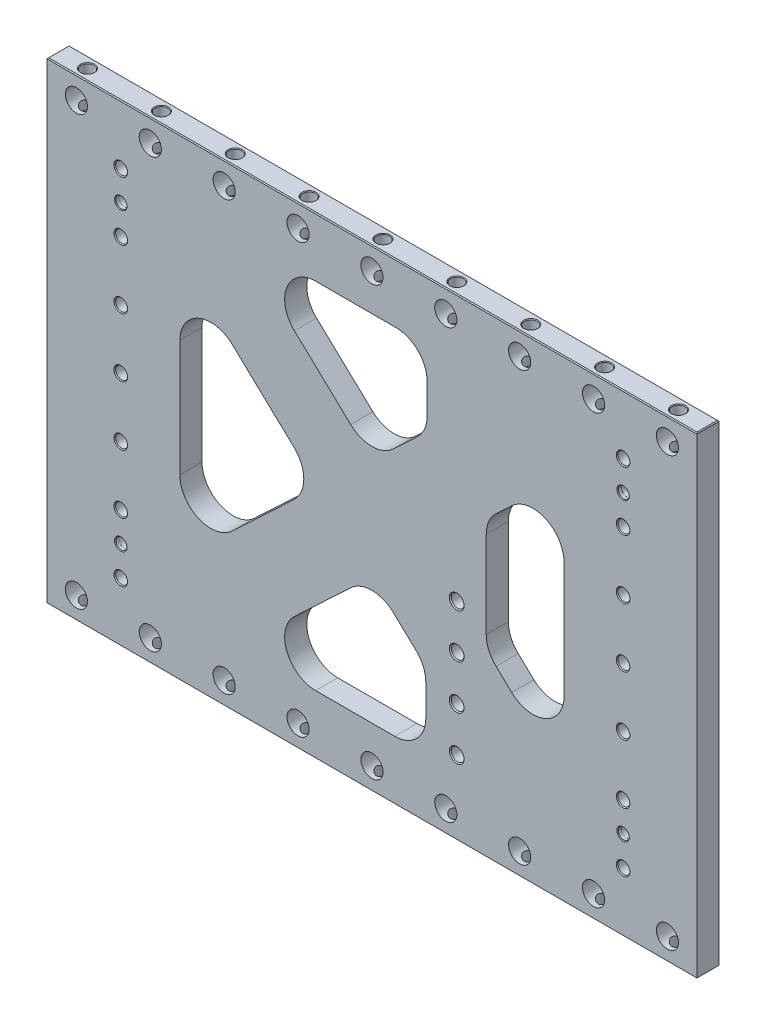
from build123d import *

# Parameters (mm, degrees)
SKETCH2_W                                = 558.8
SKETCH2_H                                = 406.4
EXTRUDE1_DEPTH                           = 9.525
TRIANGLES_CUT_EXTRUDE2_DEPTH             = 20.05
TRIANGLES_FILLET1_R                      = 26.67
LPATTERN3_COUNT                          = 4
LPATTERN3_PITCH                          = 50.8
LPATTERN3_COL_COUNT                      = 4
LPATTERN3_COL_PITCH                      = 50.8
F_3_4_0_75_DIAMETER_HOLE1_D              = 19.05
LPATTERN4_COUNT                          = 5
LPATTERN4_PITCH                          = 63.5
LPATTERN4_COL_COUNT                      = 5
LPATTERN4_COL_PITCH                      = 63.5
MIRROR2_COPY_1_D                         = 19.05
MIRROR2_COPY_2_D                         = 19.05
MIRROR2_COPY_3_D                         = 19.05
MIRROR2_COPY_4_D                         = 19.05
MIRROR2_COPY_9_D                         = 19.05
MIRROR2_COPY_10_D                        = 19.05
MIRROR2_COPY_11_D                        = 19.05
MIRROR2_COPY_12_D                        = 19.05
LPATTERN5_COUNT                          = 4
LPATTERN5_PITCH                          = 38.1
F_3_8_0_375_PIN_LEAD_IN_HOLE1_AT_2_COUNT = 2
F_3_8_0_375_PIN_LEAD_IN_HOLE1_AT_2_PITCH = 431.8
F_3_8_0_375_PIN_LEAD_IN_HOLE1_AT_3_COUNT = 2
F_3_8_0_375_PIN_LEAD_IN_HOLE1_AT_3_PITCH = 500.966306252
F_3_8_0_375_PIN_LEAD_IN_HOLE1_AT_4_COUNT = 2
F_3_8_0_375_PIN_LEAD_IN_HOLE1_AT_4_PITCH = 254
CHAMFER1_SIZE                            = 0.762


with BuildPart() as part:
    # Sketch2 → Extrude1 (new body, symmetric)
    with BuildSketch(Plane.XY):
        Rectangle(SKETCH2_W, SKETCH2_H)
    extrude(amount=EXTRUDE1_DEPTH, both=True)

    # Sketch8 → Triangles -- Cut-Extrude2 (cut, through all)
    with BuildSketch(Plane.XY.offset(9.525)):
        Polygon((-165.1, 111.787575697), (-46.325700822, 0), (-165.1, -111.787575697), align=None)
        Polygon((-115.599299178, 152.4), (0, 43.600659597), (47.466504, 88.275016303), (47.466504, 152.4), align=None)
        Polygon((165.1, 111.787575697), (165.1, -111.787575697), (98.266504, -48.885461815), (98.266504, 48.885461815), align=None)
        Polygon((0, -43.600659597), (-115.599299178, -152.4), (46.325700822, -152.4), (46.325700822, -87.201319194), align=None)
    extrude(amount=-TRIANGLES_CUT_EXTRUDE2_DEPTH, mode=Mode.SUBTRACT)

    # Triangles -- Fillet1
    triangles_fillet1_edges = [part.edges().sort_by_distance(p)[0] for p in [
        (-165.1, -111.787575697, 0),
        (-165.1, 111.787575697, 0),
        (-46.325700822, 0, 0),
        (-115.599299178, 152.4, 0),
        (47.466504, 152.4, 0),
        (47.466504, 88.275016303, 0),
        (0, 43.600659597, 0),
        (98.266504, 48.885461815, 0),
        (165.1, 111.787575697, 0),
        (165.1, -111.787575697, 0),
        (98.266504, -48.885461815, 0),
        (0, -43.600659597, 0),
        (46.325700822, -87.201319194, 0),
        (46.325700822, -152.4, 0),
        (-115.599299178, -152.4, 0),
    ]]
    fillet(triangles_fillet1_edges, radius=TRIANGLES_FILLET1_R)

    # Sketch3 → CBORE for 3/8 Socket Head Cap Screw2 (revolve, cut)
    with BuildSketch(Plane(origin=(-215.9, 0, -9.525), x_dir=(0, 1, 0), z_dir=(1, 0, 0))):
        Polygon((0, 0), (0, 19.05), (5.842, 19.05), (5.15874, 18.263999282), (5.15874, 4.318), (8.73125, 4.318), (8.73125, 0), align=None)
    cbore_for_3_8_socket_head_cap_screw2 = revolve(axis=Axis((-215.9, 0, -15.875), (0, 0, 1)), mode=Mode.SUBTRACT)

    # LPattern3: CBORE for 3/8 Socket Head Cap Screw2 ×4
    with Locations(*[(0, i * LPATTERN3_PITCH, 0) for i in range(1, LPATTERN3_COUNT)]):
        add(cbore_for_3_8_socket_head_cap_screw2, mode=Mode.SUBTRACT)

    # LPattern3 col: CBORE for 3/8 Socket Head Cap Screw2 ×4
    with Locations(*[(0, -i * LPATTERN3_COL_PITCH, 0) for i in range(1, LPATTERN3_COL_COUNT)]):
        add(cbore_for_3_8_socket_head_cap_screw2, mode=Mode.SUBTRACT)

    # Mirror1: CBORE for 3/8 Socket Head Cap Screw2 across plane
    add(cbore_for_3_8_socket_head_cap_screw2.mirror(Plane(origin=(0, 0, 0), x_dir=(0, 0, 1), z_dir=(1, 0, 0))), mode=Mode.SUBTRACT)

    # Mirror1 copy 1 sketch → Mirror1 copy 1 (revolve, cut)
    with BuildSketch(Plane(origin=(215.9, 50.8, -9.525), x_dir=(0, 1, 0), z_dir=(-1, 0, 0))):
        Polygon((0, 0), (0, -19.05), (5.842, -19.05), (5.15874, -18.263999282), (5.15874, -4.318), (8.73125, -4.318), (8.73125, 0), align=None)
    revolve(axis=Axis((215.9, 50.8, -15.875), (0, 0, -1)), mode=Mode.SUBTRACT)

    # Mirror1 copy 2 sketch → Mirror1 copy 2 (revolve, cut)
    with BuildSketch(Plane(origin=(215.9, 101.6, -9.525), x_dir=(0, 1, 0), z_dir=(-1, 0, 0))):
        Polygon((0, 0), (0, -19.05), (5.842, -19.05), (5.15874, -18.263999282), (5.15874, -4.318), (8.73125, -4.318), (8.73125, 0), align=None)
    revolve(axis=Axis((215.9, 101.6, -15.875), (0, 0, -1)), mode=Mode.SUBTRACT)

    # Mirror1 copy 3 sketch → Mirror1 copy 3 (revolve, cut)
    with BuildSketch(Plane(origin=(215.9, 152.4, -9.525), x_dir=(0, 1, 0), z_dir=(-1, 0, 0))):
        Polygon((0, 0), (0, -19.05), (5.842, -19.05), (5.15874, -18.263999282), (5.15874, -4.318), (8.73125, -4.318), (8.73125, 0), align=None)
    revolve(axis=Axis((215.9, 152.4, -15.875), (0, 0, -1)), mode=Mode.SUBTRACT)

    # Mirror1 copy 4 sketch → Mirror1 copy 4 (revolve, cut)
    with BuildSketch(Plane(origin=(215.9, -50.8, -9.525), x_dir=(0, 1, 0), z_dir=(-1, 0, 0))):
        Polygon((0, 0), (0, -19.05), (5.842, -19.05), (5.15874, -18.263999282), (5.15874, -4.318), (8.73125, -4.318), (8.73125, 0), align=None)
    revolve(axis=Axis((215.9, -50.8, -15.875), (0, 0, -1)), mode=Mode.SUBTRACT)

    # Mirror1 copy 5 sketch → Mirror1 copy 5 (revolve, cut)
    with BuildSketch(Plane(origin=(215.9, -101.6, -9.525), x_dir=(0, 1, 0), z_dir=(-1, 0, 0))):
        Polygon((0, 0), (0, -19.05), (5.842, -19.05), (5.15874, -18.263999282), (5.15874, -4.318), (8.73125, -4.318), (8.73125, 0), align=None)
    revolve(axis=Axis((215.9, -101.6, -15.875), (0, 0, -1)), mode=Mode.SUBTRACT)

    # Mirror1 copy 6 sketch → Mirror1 copy 6 (revolve, cut)
    with BuildSketch(Plane(origin=(215.9, -152.4, -9.525), x_dir=(0, 1, 0), z_dir=(-1, 0, 0))):
        Polygon((0, 0), (0, -19.05), (5.842, -19.05), (5.15874, -18.263999282), (5.15874, -4.318), (8.73125, -4.318), (8.73125, 0), align=None)
    revolve(axis=Axis((215.9, -152.4, -15.875), (0, 0, -1)), mode=Mode.SUBTRACT)

    # 3/4 (0.75) Diameter Hole1 (through all)
    with Locations(Plane.XY.offset(9.525)):
        with Locations((0, -184.15)):
            f_3_4_0_75_diameter_hole1 = Hole(F_3_4_0_75_DIAMETER_HOLE1_D / 2)

    # Sketch12 → 7/16 (0.4375) Diameter Hole1 (revolve, cut)
    with BuildSketch(Plane(origin=(0, -203.2, 0), x_dir=(0, 0, -1), z_dir=(1, 0, 0))):
        Polygon((0, 0), (0, 38.263531814), (5.55625, 34.925), (5.55625, 0.620911348), (6.096, 0), align=None)
    f_7_16_0_4375_diameter_hole1 = revolve(axis=Axis((0, -209.55, 0), (0, 1, 0)), mode=Mode.SUBTRACT)

    # LPattern4: 3/4 (0.75) Diameter Hole1, 7/16 (0.4375) Diameter Hole1 ×5
    with Locations(*[(i * LPATTERN4_PITCH, 0, 0) for i in range(1, LPATTERN4_COUNT)]):
        add(f_3_4_0_75_diameter_hole1, mode=Mode.SUBTRACT)
        add(f_7_16_0_4375_diameter_hole1, mode=Mode.SUBTRACT)

    # LPattern4 col: 3/4 (0.75) Diameter Hole1, 7/16 (0.4375) Diameter Hole1 ×5
    with Locations(*[(-i * LPATTERN4_COL_PITCH, 0, 0) for i in range(1, LPATTERN4_COL_COUNT)]):
        add(f_3_4_0_75_diameter_hole1, mode=Mode.SUBTRACT)
        add(f_7_16_0_4375_diameter_hole1, mode=Mode.SUBTRACT)

    # Mirror2: 3/4 (0.75) Diameter Hole1, 7/16 (0.4375) Diameter Hole1 across plane
    add(f_3_4_0_75_diameter_hole1.mirror(Plane.ZX), mode=Mode.SUBTRACT)
    add(f_7_16_0_4375_diameter_hole1.mirror(Plane.ZX), mode=Mode.SUBTRACT)

    # Mirror2 copy 1 (through all)
    with Locations(Plane(origin=(63.5, 0, 9.525), x_dir=(1, 0, 0), z_dir=(0, 0, 1))):
        with Locations((0, 184.15)):
            Hole(MIRROR2_COPY_1_D / 2)

    # Mirror2 copy 2 (through all)
    with Locations(Plane(origin=(127, 0, 9.525), x_dir=(1, 0, 0), z_dir=(0, 0, 1))):
        with Locations((0, 184.15)):
            Hole(MIRROR2_COPY_2_D / 2)

    # Mirror2 copy 3 (through all)
    with Locations(Plane(origin=(190.5, 0, 9.525), x_dir=(1, 0, 0), z_dir=(0, 0, 1))):
        with Locations((0, 184.15)):
            Hole(MIRROR2_COPY_3_D / 2)

    # Mirror2 copy 4 (through all)
    with Locations(Plane(origin=(254, 0, 9.525), x_dir=(1, 0, 0), z_dir=(0, 0, 1))):
        with Locations((0, 184.15)):
            Hole(MIRROR2_COPY_4_D / 2)

    # Mirror2 copy 5 sketch → Mirror2 copy 5 (revolve, cut)
    with BuildSketch(Plane(origin=(63.5, 203.2, 0), x_dir=(0, 0, -1), z_dir=(1, 0, 0))):
        Polygon((0, 0), (0, -38.263531814), (5.55625, -34.925), (5.55625, -0.620911348), (6.096, 0), align=None)
    revolve(axis=Axis((63.5, 209.55, 0), (0, 1, 0)), mode=Mode.SUBTRACT)

    # Mirror2 copy 6 sketch → Mirror2 copy 6 (revolve, cut)
    with BuildSketch(Plane(origin=(127, 203.2, 0), x_dir=(0, 0, -1), z_dir=(1, 0, 0))):
        Polygon((0, 0), (0, -38.263531814), (5.55625, -34.925), (5.55625, -0.620911348), (6.096, 0), align=None)
    revolve(axis=Axis((127, 209.55, 0), (0, 1, 0)), mode=Mode.SUBTRACT)

    # Mirror2 copy 7 sketch → Mirror2 copy 7 (revolve, cut)
    with BuildSketch(Plane(origin=(190.5, 203.2, 0), x_dir=(0, 0, -1), z_dir=(1, 0, 0))):
        Polygon((0, 0), (0, -38.263531814), (5.55625, -34.925), (5.55625, -0.620911348), (6.096, 0), align=None)
    revolve(axis=Axis((190.5, 209.55, 0), (0, 1, 0)), mode=Mode.SUBTRACT)

    # Mirror2 copy 8 sketch → Mirror2 copy 8 (revolve, cut)
    with BuildSketch(Plane(origin=(254, 203.2, 0), x_dir=(0, 0, -1), z_dir=(1, 0, 0))):
        Polygon((0, 0), (0, -38.263531814), (5.55625, -34.925), (5.55625, -0.620911348), (6.096, 0), align=None)
    revolve(axis=Axis((254, 209.55, 0), (0, 1, 0)), mode=Mode.SUBTRACT)

    # Mirror2 copy 9 (through all)
    with Locations(Plane(origin=(-63.5, 0, 9.525), x_dir=(1, 0, 0), z_dir=(0, 0, 1))):
        with Locations((0, 184.15)):
            Hole(MIRROR2_COPY_9_D / 2)

    # Mirror2 copy 10 (through all)
    with Locations(Plane(origin=(-127, 0, 9.525), x_dir=(1, 0, 0), z_dir=(0, 0, 1))):
        with Locations((0, 184.15)):
            Hole(MIRROR2_COPY_10_D / 2)

    # Mirror2 copy 11 (through all)
    with Locations(Plane(origin=(-190.5, 0, 9.525), x_dir=(1, 0, 0), z_dir=(0, 0, 1))):
        with Locations((0, 184.15)):
            Hole(MIRROR2_COPY_11_D / 2)

    # Mirror2 copy 12 (through all)
    with Locations(Plane(origin=(-254, 0, 9.525), x_dir=(1, 0, 0), z_dir=(0, 0, 1))):
        with Locations((0, 184.15)):
            Hole(MIRROR2_COPY_12_D / 2)

    # Mirror2 copy 13 sketch → Mirror2 copy 13 (revolve, cut)
    with BuildSketch(Plane(origin=(-63.5, 203.2, 0), x_dir=(0, 0, -1), z_dir=(1, 0, 0))):
        Polygon((0, 0), (0, -38.263531814), (5.55625, -34.925), (5.55625, -0.620911348), (6.096, 0), align=None)
    revolve(axis=Axis((-63.5, 209.55, 0), (0, 1, 0)), mode=Mode.SUBTRACT)

    # Mirror2 copy 14 sketch → Mirror2 copy 14 (revolve, cut)
    with BuildSketch(Plane(origin=(-127, 203.2, 0), x_dir=(0, 0, -1), z_dir=(1, 0, 0))):
        Polygon((0, 0), (0, -38.263531814), (5.55625, -34.925), (5.55625, -0.620911348), (6.096, 0), align=None)
    revolve(axis=Axis((-127, 209.55, 0), (0, 1, 0)), mode=Mode.SUBTRACT)

    # Mirror2 copy 15 sketch → Mirror2 copy 15 (revolve, cut)
    with BuildSketch(Plane(origin=(-190.5, 203.2, 0), x_dir=(0, 0, -1), z_dir=(1, 0, 0))):
        Polygon((0, 0), (0, -38.263531814), (5.55625, -34.925), (5.55625, -0.620911348), (6.096, 0), align=None)
    revolve(axis=Axis((-190.5, 209.55, 0), (0, 1, 0)), mode=Mode.SUBTRACT)

    # Mirror2 copy 16 sketch → Mirror2 copy 16 (revolve, cut)
    with BuildSketch(Plane(origin=(-254, 203.2, 0), x_dir=(0, 0, -1), z_dir=(1, 0, 0))):
        Polygon((0, 0), (0, -38.263531814), (5.55625, -34.925), (5.55625, -0.620911348), (6.096, 0), align=None)
    revolve(axis=Axis((-254, 209.55, 0), (0, 1, 0)), mode=Mode.SUBTRACT)

    # Sketch18 → CBORE for 3/8 Socket Head Cap Screw1 (revolve, cut)
    with BuildSketch(Plane(origin=(72.866504, -139.7, -9.525), x_dir=(0, 1, 0), z_dir=(1, 0, 0))):
        Polygon((0, 0), (0, 19.05), (6.35, 19.05), (5.55625, 18.136895077), (5.55625, 4.318), (9.128125, 4.318), (9.128125, 0), align=None)
    cbore_for_3_8_socket_head_cap_screw1 = revolve(axis=Axis((72.866504, -139.7, -15.875), (0, 0, 1)), mode=Mode.SUBTRACT)

    # LPattern5: CBORE for 3/8 Socket Head Cap Screw1 ×4
    with Locations(*[(0, i * LPATTERN5_PITCH, 0) for i in range(1, LPATTERN5_COUNT)]):
        add(cbore_for_3_8_socket_head_cap_screw1, mode=Mode.SUBTRACT)

    # Sketch21 → 3/8 (0.375) Pin + Lead-In Hole1 (revolve, cut)
    with BuildSketch(Plane(origin=(-215.9, 127, 9.525), x_dir=(0, -1, 0), z_dir=(1, 0, 0))):
        Polygon((0, 0), (0, 19.05), (4.7625, 19.05), (4.7625, 3.175), (4.7879, 3.175), (4.7879, 0.628216187), (5.334, 0), align=None)
    f_3_8_0_375_pin_lead_in_hole1 = revolve(axis=Axis((-215.9, 127, 15.875), (0, 0, -1)), mode=Mode.SUBTRACT)

    # 3/8 (0.375) Pin + Lead-In Hole1 at 2: 3/8 (0.375) Pin + Lead-In Hole1 ×2
    with Locations(*[(i * F_3_8_0_375_PIN_LEAD_IN_HOLE1_AT_2_PITCH, 0, 0) for i in range(1, F_3_8_0_375_PIN_LEAD_IN_HOLE1_AT_2_COUNT)]):
        add(f_3_8_0_375_pin_lead_in_hole1, mode=Mode.SUBTRACT)

    # 3/8 (0.375) Pin + Lead-In Hole1 at 3: 3/8 (0.375) Pin + Lead-In Hole1 ×2
    with Locations(*[Vector(0.861934215, -0.507020127, 0) * (i * F_3_8_0_375_PIN_LEAD_IN_HOLE1_AT_3_PITCH) for i in range(1, F_3_8_0_375_PIN_LEAD_IN_HOLE1_AT_3_COUNT)]):
        add(f_3_8_0_375_pin_lead_in_hole1, mode=Mode.SUBTRACT)

    # 3/8 (0.375) Pin + Lead-In Hole1 at 4: 3/8 (0.375) Pin + Lead-In Hole1 ×2
    with Locations(*[(0, -i * F_3_8_0_375_PIN_LEAD_IN_HOLE1_AT_4_PITCH, 0) for i in range(1, F_3_8_0_375_PIN_LEAD_IN_HOLE1_AT_4_COUNT)]):
        add(f_3_8_0_375_pin_lead_in_hole1, mode=Mode.SUBTRACT)

    # Chamfer1
    chamfer1_edges = [part.edges().sort_by_distance(p)[0] for p in [
        (0, 203.2, 9.525),
        (0, 203.2, -9.525),
        (0, -203.2, -9.525),
        (0, -203.2, 9.525),
        (-279.4, 203.2, 0),
        (279.4, 203.2, 0),
        (279.4, -203.2, 0),
        (-279.4, -203.2, 0),
    ]]
    chamfer(chamfer1_edges, length=CHAMFER1_SIZE)


solid = part.part
